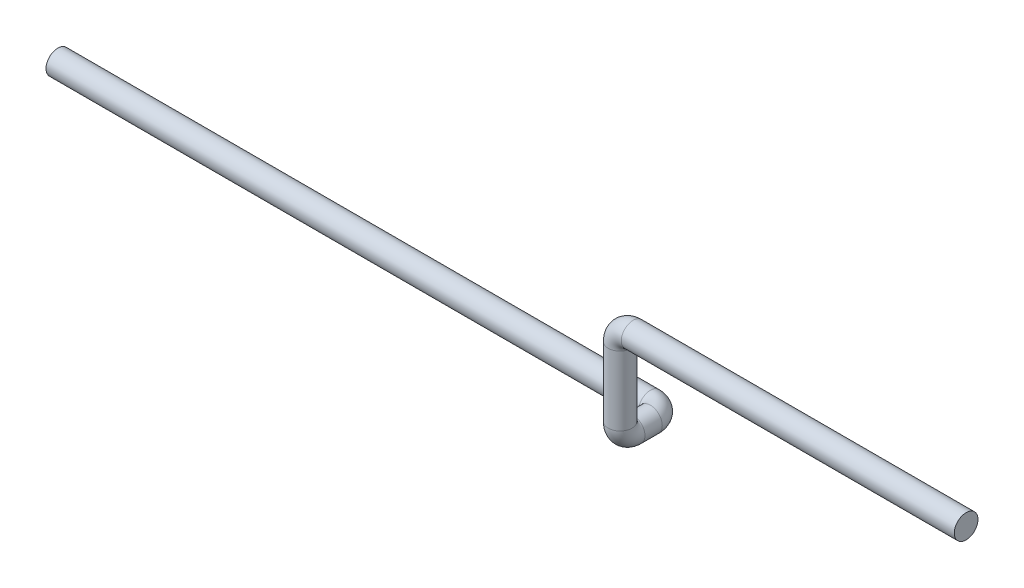
from build123d import *

# Parameters (mm, degrees)
CROQUIS1_R = 13.7


with BuildPart() as part:
    # Barrer1: sweep along a curve in space
    with BuildLine() as barrer1_path:
        Line((0, 0, 0), (-385, 0, 0))
        ThreePointArc((-385, 0, 0), (-395.606601718, -4.393398282, 0), (-400, -15, 0))
        Line((-400, -15, 0), (-400, -95, 0))
        ThreePointArc((-400, -95, 0), (-400, -105.606601718, -4.393398282), (-400, -110, -15))
        Line((-400, -110, -15), (-400, -110, -35))
        ThreePointArc((-400, -110, -35), (-404.393398282, -110, -45.606601718), (-415, -110, -50))
        Line((-415, -110, -50), (-1100, -110, -50))
    # Croquis1 → Barrer1 (sweep)
    with BuildSketch(Plane(origin=(0, 0, 0), x_dir=(0, 0, -1), z_dir=(1, 0, 0))):
        Circle(CROQUIS1_R)
    sweep(path=barrer1_path.line)


solid = part.part
